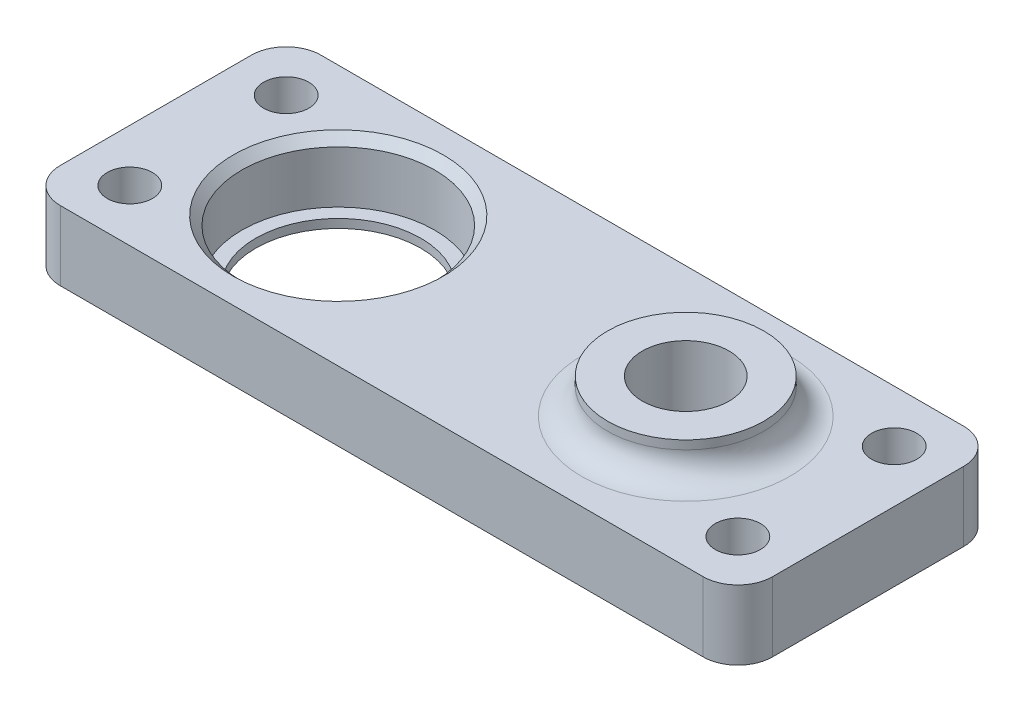
from build123d import *

# Parameters (mm, degrees)
SKETCH1_R           = 9.5
SKETCH1_R_2         = 5
SKETCH1_R_3         = 2.6
BOSS_EXTRUDE1_DEPTH = 8
SKETCH2_R           = 11.1
CUT_EXTRUDE1_DEPTH  = 7
SKETCH3_R           = 9
SKETCH3_R_2         = 5
BOSS_EXTRUDE2_DEPTH = 4
FILLET1_R           = 3
CHAMFER1_SIZE       = 1


with BuildPart() as part:
    # Sketch1 → Boss-Extrude1 (new body)
    with BuildSketch(Plane(origin=(0, 0, 0), x_dir=(1, 0, 0), z_dir=(0, 1, 0))):
        with BuildLine():
            Line((-17, 15), (57, 15))
            ThreePointArc((57, 15), (59.828427125, 13.828427125), (61, 11))
            Line((61, 11), (61, -11))
            ThreePointArc((61, -11), (59.828427125, -13.828427125), (57, -15))
            Line((57, -15), (-17, -15))
            ThreePointArc((-17, -15), (-19.828427125, -13.828427125), (-21, -11))
            Line((-21, -11), (-21, 11))
            ThreePointArc((-21, 11), (-19.828427125, 13.828427125), (-17, 15))
        make_face()
        with Locations(Location((0, 0, 0), (0, 0, 270))):  # turned: the seam where the file's is
            Circle(SKETCH1_R, mode=Mode.SUBTRACT)
        with Locations(Location((40, 0, 0), (0, 0, 270))):  # turned: the seam where the file's is
            Circle(SKETCH1_R_2, mode=Mode.SUBTRACT)
        with Locations(Location((-15, 9, 0), (0, 0, 270))):  # turned: the seam where the file's is
            Circle(SKETCH1_R_3, mode=Mode.SUBTRACT)
        with Locations(Location((-15, -9, 0), (0, 0, 270))):  # turned: the seam where the file's is
            Circle(SKETCH1_R_3, mode=Mode.SUBTRACT)
        with Locations(Location((55, 9, 0), (0, 0, 270))):  # turned: the seam where the file's is
            Circle(SKETCH1_R_3, mode=Mode.SUBTRACT)
        with Locations(Location((55, -9, 0), (0, 0, 270))):  # turned: the seam where the file's is
            Circle(SKETCH1_R_3, mode=Mode.SUBTRACT)
    extrude(amount=BOSS_EXTRUDE1_DEPTH)

    # Sketch2 → Cut-Extrude1 (cut)
    with BuildSketch(Plane(origin=(0, 8, 0), x_dir=(1, 0, 0), z_dir=(0, 1, 0))):
        with Locations(Location((0, 0, 0), (0, 0, 270))):  # turned: the seam where the file's is
            Circle(SKETCH2_R)
    extrude(amount=-CUT_EXTRUDE1_DEPTH, mode=Mode.SUBTRACT)

    # Sketch3 → Boss-Extrude2 (add)
    with BuildSketch(Plane(origin=(0, 8, 0), x_dir=(1, 0, 0), z_dir=(0, 1, 0))):
        with Locations(Location((40, 0, 0), (0, 0, 90))):  # turned: the seam where the file's is
            Circle(SKETCH3_R)
        with Locations(Location((40, 0, 0), (0, 0, 270))):  # turned: the seam where the file's is
            Circle(SKETCH3_R_2, mode=Mode.SUBTRACT)
    extrude(amount=BOSS_EXTRUDE2_DEPTH)

    # Fillet1
    fillet1_edges = [part.edges().sort_by_distance(p)[0] for p in [
        (40, 8, 9),
    ]]
    fillet(fillet1_edges, radius=FILLET1_R)

    # Chamfer1
    chamfer1_edges = [part.edges().sort_by_distance(p)[0] for p in [
        (0, 8, -11.1),
    ]]
    chamfer(chamfer1_edges, length=CHAMFER1_SIZE)


solid = part.part
